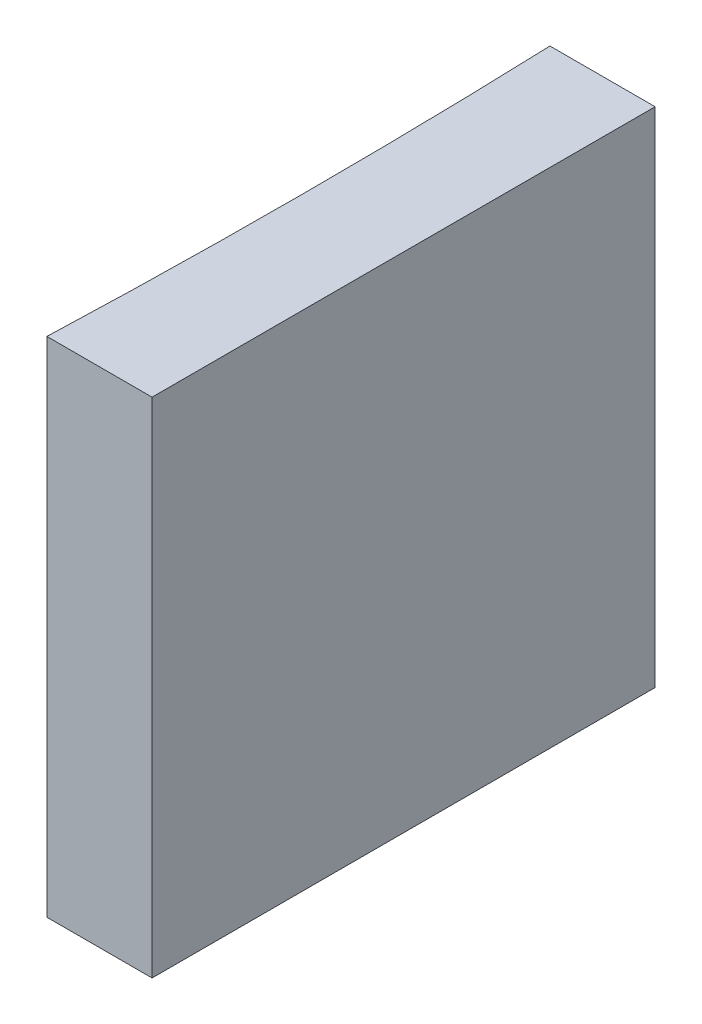
from build123d import *

# Parameters (mm, degrees)
EXTRUDE_1_DEPTH = 10


with BuildPart() as part:
    # 草图1 → 凸台-拉伸1 (new body)
    with BuildSketch(Plane(origin=(0, 0, 0), x_dir=(1, 0, 0), z_dir=(0, 1, 0))):
        with BuildLine():
            Line((0, 0), (0, -10))
            Line((0, -10), (-2.090906085, -10))
            ThreePointArc((-2.090906085, -10), (-2, -5), (-2.090906085, 0))
            Line((-2.090906085, 0), (0, 0))
        make_face()
    extrude(amount=EXTRUDE_1_DEPTH)


solid = part.part
